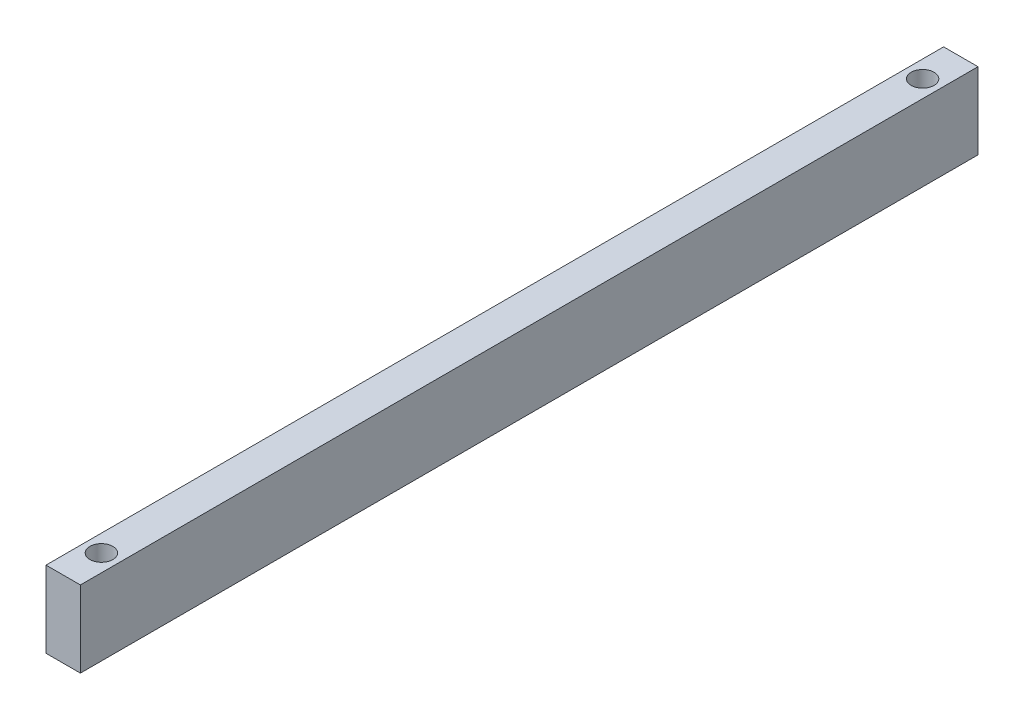
from build123d import *

# Parameters (mm, degrees)
SKETCH1_W           = 9
SKETCH1_H           = 20
BOSS_EXTRUDE1_DEPTH = 117.5
SKETCH3_R           = 3
CUT_EXTRUDE2_DEPTH  = 21


with BuildPart() as part:
    # Sketch1 → Boss-Extrude1 (new body, symmetric)
    with BuildSketch(Plane.XY):
        Rectangle(SKETCH1_W, SKETCH1_H)
    extrude(amount=BOSS_EXTRUDE1_DEPTH, both=True)

    # Sketch3 → Cut-Extrude2 (cut, through all)
    with BuildSketch(Plane(origin=(0, 10, 0), x_dir=(1, 0, 0), z_dir=(0, 1, 0))):
        with Locations((0, -107.5)):
            Circle(SKETCH3_R)
    cut_extrude2 = extrude(amount=-CUT_EXTRUDE2_DEPTH, mode=Mode.SUBTRACT)

    # Mirror2: Cut-Extrude2 across plane
    add(cut_extrude2.mirror(Plane.XY), mode=Mode.SUBTRACT)


solid = part.part
